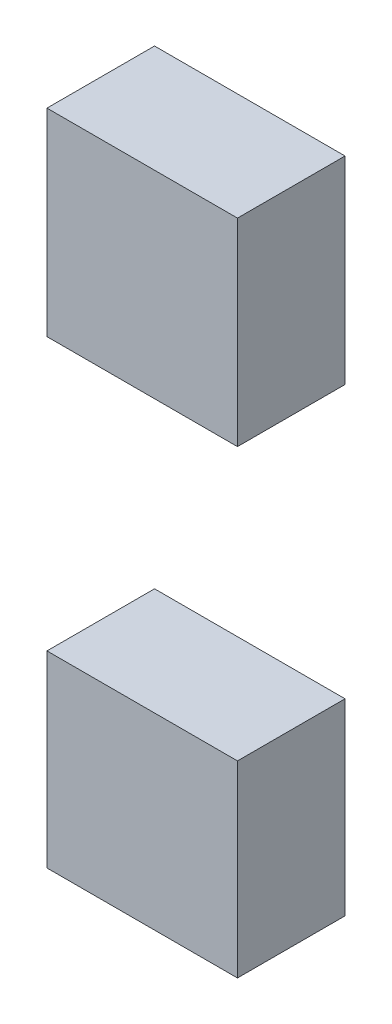
from build123d import *

# Parameters (mm, degrees)
SKETCH1_W             = 17.710303816
SKETCH1_H             = 18.400315652
BOSS_EXTRUDE1_DEPTH   = 10
SKETCH1_H_2           = 17.480299869
BOSS_EXTRUDE1_2_DEPTH = 10


with BuildPart() as part:
    # Sketch1 → Boss-Extrude1 (new body)
    with BuildSketch(Plane.XY):
        with Locations((0, 21.620370891)):
            Rectangle(SKETCH1_W, SKETCH1_H)
    extrude(amount=BOSS_EXTRUDE1_DEPTH)


with BuildPart() as body_2:
    # Sketch1 → Boss-Extrude1 2 (new body)
    with BuildSketch(Plane.XY):
        with Locations((0, -21.620370892)):
            Rectangle(SKETCH1_W, SKETCH1_H_2)
    extrude(amount=BOSS_EXTRUDE1_2_DEPTH)


solid = Compound([part.part, body_2.part])
